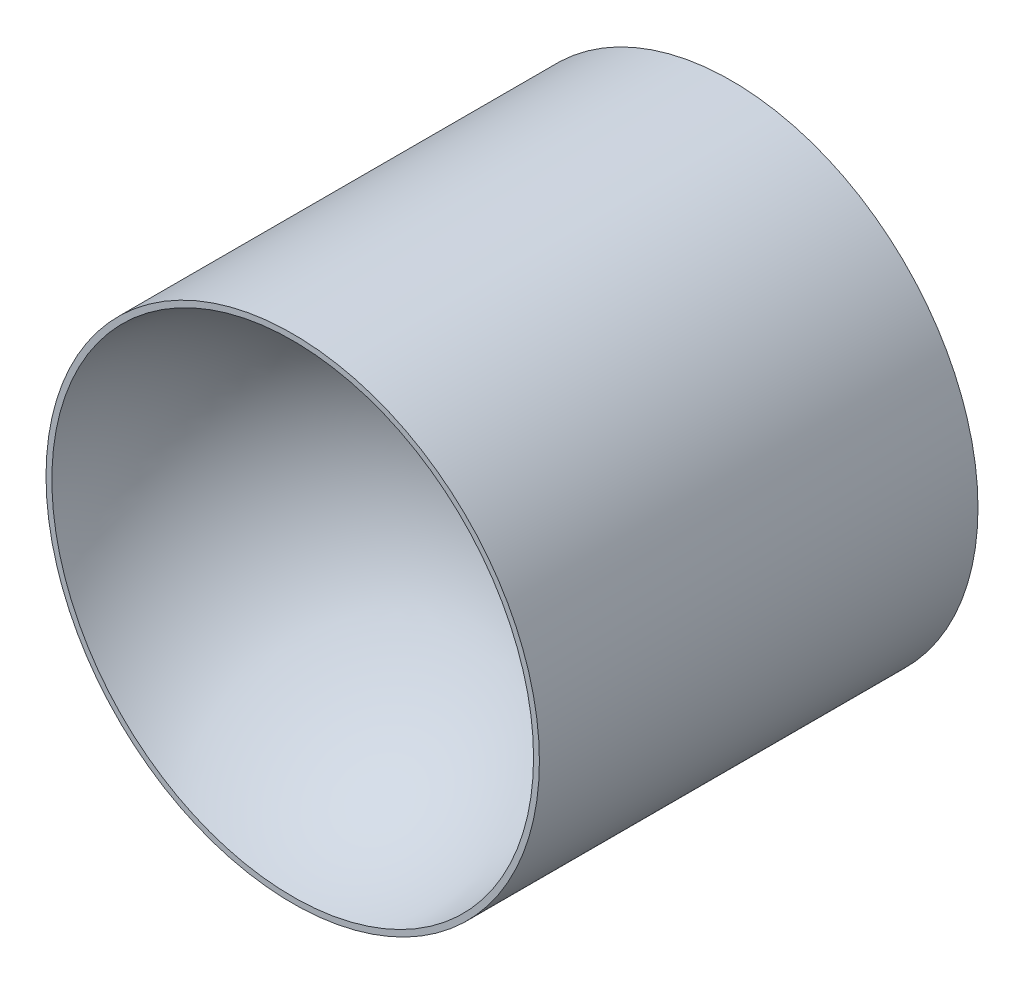
from build123d import *

# Parameters (mm, degrees)
SKETCH2_R           = 36
BOSS_EXTRUDE1_DEPTH = 74
CUT_REVOLVE1_ANGLE  = 180
CUT_EXTRUDE1_REACH  = 12
SKETCH5_W           = 97.630906447
SKETCH5_H           = 85.301230118
SKETCH6_R           = 11.5
CUT_EXTRUDE2_DEPTH  = 2.5


with BuildPart() as part:
    # Sketch2 → Boss-Extrude1 (new body)
    with BuildSketch(Plane.XY):
        Circle(SKETCH2_R)
    extrude(amount=BOSS_EXTRUDE1_DEPTH)

    # Sketch4 → Cut-Revolve1 (revolve, cut)
    with BuildSketch(Plane.XY.offset(69)):
        with BuildLine():
            Line((-35.5, 0), (35.5, 0))
            ThreePointArc((35.5, 0), (0, 35.5), (-35.5, 0))
        make_face()
    revolve(axis=Axis((-35.5, 0, 69), (-1, 0, 0)), revolution_arc=CUT_REVOLVE1_ANGLE, mode=Mode.SUBTRACT)

    # Sketch5 → Cut-Extrude1 (cut, up to next)
    with BuildSketch(Plane.XY.offset(64), mode=Mode.PRIVATE) as cut_extrude1_sk1:
        with Locations((-1.59772985, 0.365427289)):
            Rectangle(SKETCH5_W, SKETCH5_H)
    cut_extrude1_tool1 = extrude(cut_extrude1_sk1.sketch, amount=CUT_EXTRUDE1_REACH, mode=Mode.PRIVATE) & part.part
    add(cut_extrude1_tool1.solids().sort_by_distance((-1.59773, 0.365427, 64))[0], mode=Mode.SUBTRACT)

    # Sketch6 → Cut-Extrude2 (cut)
    with BuildSketch(Plane(origin=(0, 0, 0), x_dir=(-1, 0, 0), z_dir=(0, 0, -1))):
        Circle(SKETCH6_R)
    extrude(amount=-CUT_EXTRUDE2_DEPTH, mode=Mode.SUBTRACT)


solid = part.part
